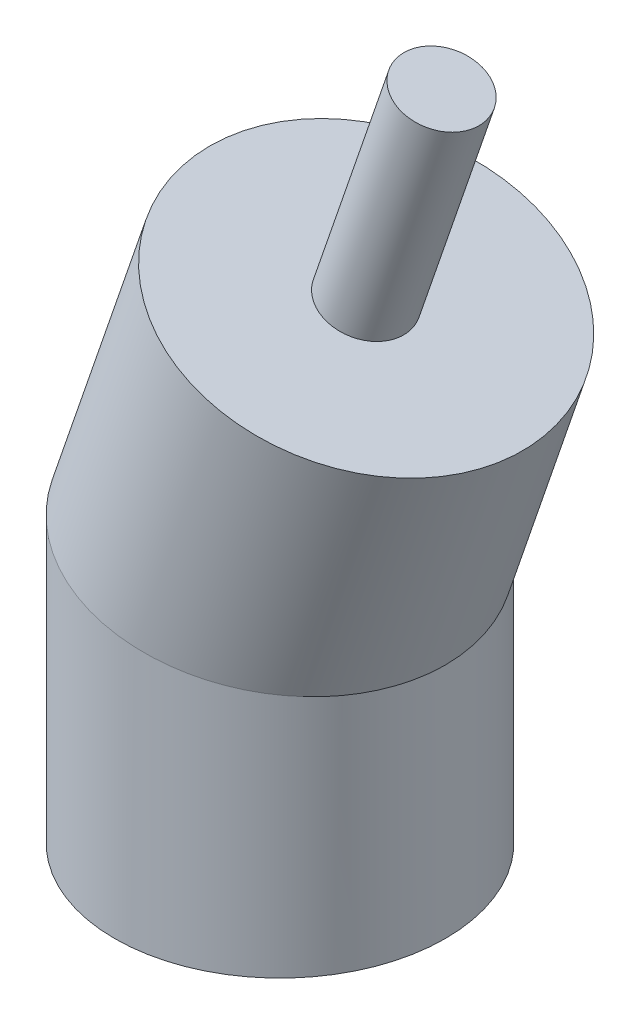
from build123d import *

# Parameters (mm, degrees)
ESBO_O2_R                = 25
ESBO_O3_R                = 6
RESSALTO_EXTRUS_O1_DEPTH = 35
ESBO_O4_R                = 6
CORTE_EXTRUS_O1_DEPTH    = 20


with BuildPart() as part:
    # Varredura1: sweep along a path in Esboço1
    with BuildLine(Plane.XY) as varredura1_path:
        Line((13.022726178, 77.820743024), (0, 40))
        Line((0, 40), (0, 0))
    # Esboço2 → Varredura1 (sweep)
    with BuildSketch(Plane(origin=(0, 0, 0), x_dir=(1, 0, 0), z_dir=(0, 1, 0))):
        Circle(ESBO_O2_R)
    sweep(path=varredura1_path.line, transition=Transition.RIGHT)

    # Esboço3 → Ressalto-extrusão1 (add)
    with BuildSketch(Plane(origin=(25.335955685, 73.580958096, 0), x_dir=(0.945518576, -0.325568154, 0), z_dir=(0.325568154, 0.945518576, 0))):
        with Locations((-13.022726178, 0)):
            Circle(ESBO_O3_R)
    extrude(amount=RESSALTO_EXTRUS_O1_DEPTH)

    # Esboço4 → Corte-extrusão1 (cut)
    with BuildSketch(Plane.XZ):
        Circle(ESBO_O4_R)
    extrude(amount=-CORTE_EXTRUS_O1_DEPTH, mode=Mode.SUBTRACT)


solid = part.part
